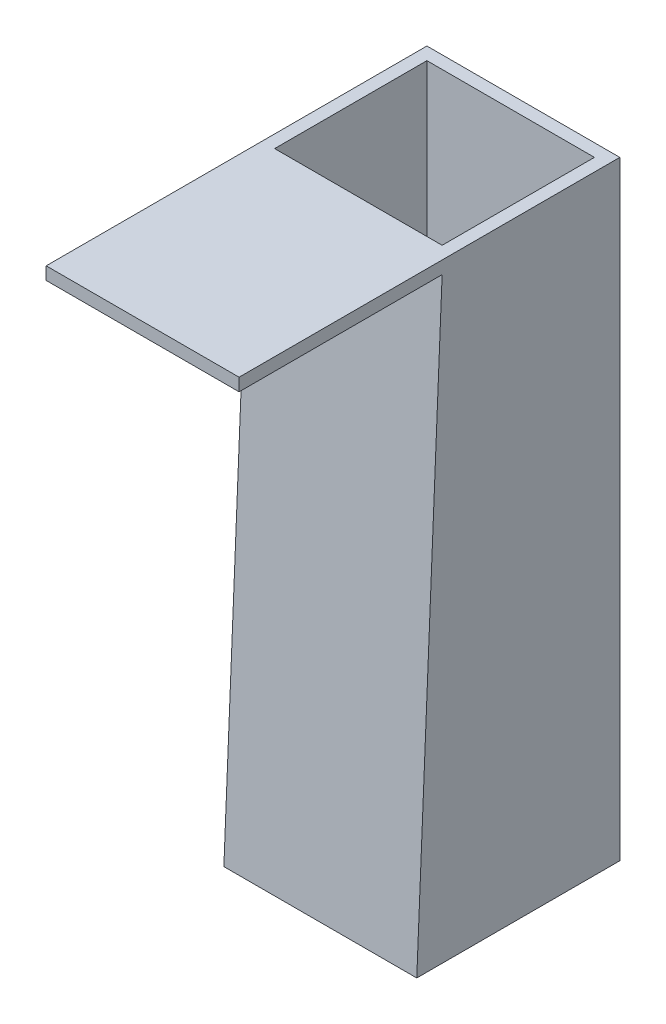
from build123d import *

# Parameters (mm, degrees)
BOSS_EXTRUDE1_DEPTH = 96.52
SKETCH2_W           = 83.82
SKETCH2_H           = 76.2
CUT_EXTRUDE1_DEPTH  = 305.8


with BuildPart() as part:
    # Sketch1 → Boss-Extrude1 (new body)
    with BuildSketch(Plane(origin=(0, 0, 0), x_dir=(0, 0, -1), z_dir=(1, 0, 0))):
        Polygon((0, 0), (12.7, 298.45), (-88.9, 298.45), (-88.9, 304.8), (101.6, 304.8), (101.6, 0), align=None)
    extrude(amount=BOSS_EXTRUDE1_DEPTH)

    # Sketch2 → Cut-Extrude1 (cut, through all)
    with BuildSketch(Plane.XZ):
        with Locations((48.26, -57.15)):
            Rectangle(SKETCH2_W, SKETCH2_H)
    extrude(amount=-CUT_EXTRUDE1_DEPTH, mode=Mode.SUBTRACT)


solid = part.part
